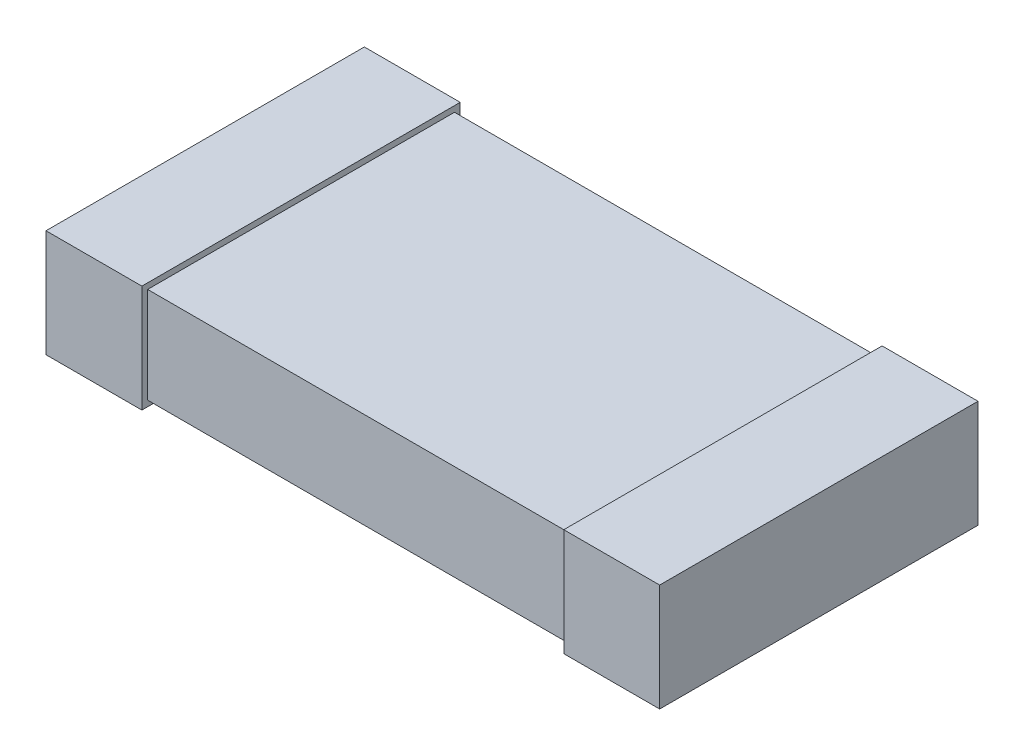
from build123d import *

# Parameters (mm, degrees)
SKETCH1_W           = 3.2
SKETCH1_H           = 1.6
EXTRUDE1_DEPTH      = 0.5
SKETCH2_W           = 0.5
SKETCH2_H           = 0.56
EXTRUDE2_DEPTH      = 0.83
EXTRUDE2_DEPTH_BACK = 0.83


with BuildPart() as part:
    # Sketch1 → Extrude1 (new body)
    with BuildSketch(Plane(origin=(0, 0, 0), x_dir=(1, 0, 0), z_dir=(0, 1, 0))):
        Rectangle(SKETCH1_W, SKETCH1_H)
    extrude(amount=EXTRUDE1_DEPTH)

    # Sketch2 → Extrude2 (add, two sides)
    with BuildSketch(Plane.XY) as extrude2_sk:
        with Locations((-1.35, 0.25)):
            Rectangle(SKETCH2_W, SKETCH2_H)
        with Locations((1.35, 0.25)):
            Rectangle(SKETCH2_W, SKETCH2_H)
    extrude(amount=EXTRUDE2_DEPTH)
    extrude(extrude2_sk.sketch, amount=-EXTRUDE2_DEPTH_BACK)


solid = part.part
